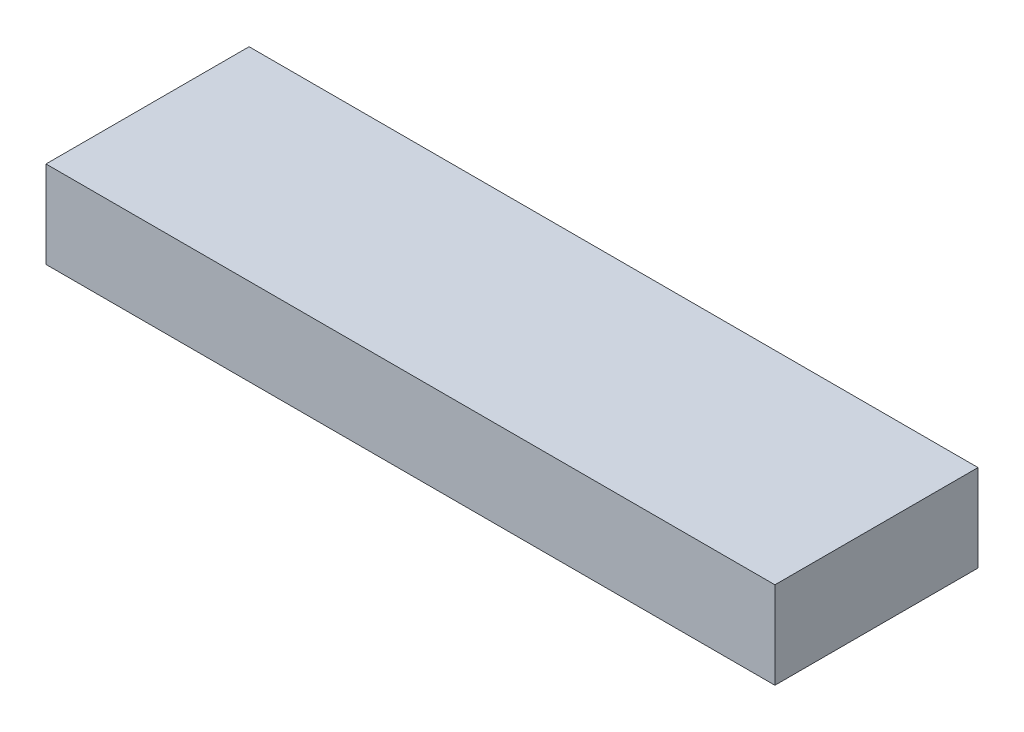
from build123d import *

# Parameters (mm, degrees)
SKETCH1_W           = 319.0875
SKETCH1_H           = 88.9
BOSS_EXTRUDE1_DEPTH = 38.1


with BuildPart() as part:
    # Sketch1 → Boss-Extrude1 (new body)
    with BuildSketch(Plane(origin=(0, 0, 0), x_dir=(1, 0, 0), z_dir=(0, 1, 0))):
        with Locations((159.54375, 44.45)):
            Rectangle(SKETCH1_W, SKETCH1_H)
    extrude(amount=BOSS_EXTRUDE1_DEPTH)


solid = part.part
